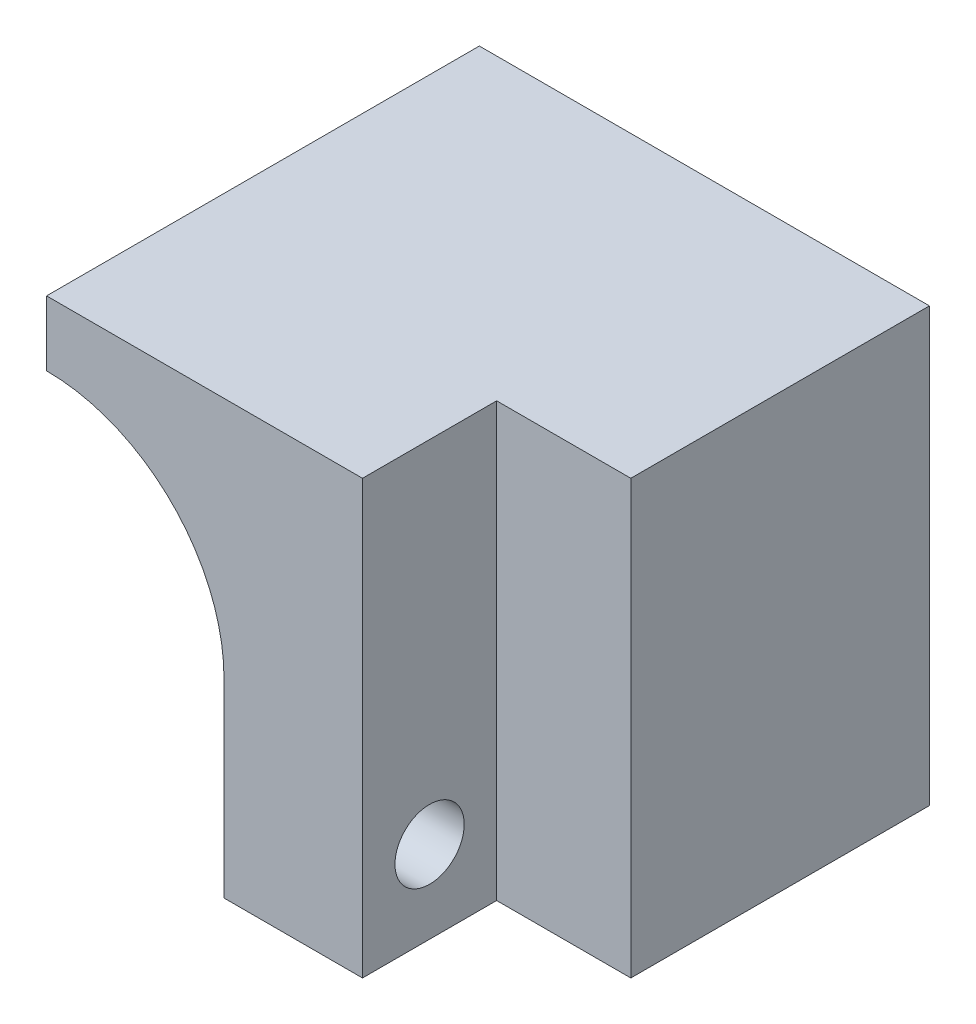
from build123d import *

# Parameters (mm, degrees)
CROQUIS1_W              = 20.8
CROQUIS1_H              = 20
SALIENTE_EXTRUIR1_DEPTH = 2
SALIENTE_EXTRUIR2_DEPTH = 11.8
SALIENTE_EXTRUIR3_DEPTH = 6.2
CORTAR_EXTRUIR1_REACH   = 16.6
CROQUIS4_R              = 1.6
CORTAR_EXTRUIR2_DEPTH   = 3


with BuildPart() as part:
    # Croquis1 → Saliente-Extruir1 (new body)
    with BuildSketch(Plane.XY):
        with Locations((10.4, -10)):
            Rectangle(CROQUIS1_W, CROQUIS1_H)
    extrude(amount=SALIENTE_EXTRUIR1_DEPTH)

    # Croquis2 → Saliente-Extruir2 (add)
    with BuildSketch(Plane.XY.offset(2)):
        with BuildLine():
            Line((8.2, -11.2), (8.2, -20))
            Line((8.2, -20), (20.8, -20))
            Line((20.8, -20), (20.8, 0))
            Line((20.8, 0), (0, 0))
            Line((0, 0), (0, -3))
            ThreePointArc((0, -3), (5.798275606, -5.401724394), (8.2, -11.2))
        make_face()
    extrude(amount=SALIENTE_EXTRUIR2_DEPTH)

    # Croquis3 → Saliente-Extruir3 (add)
    with BuildSketch(Plane.XY.offset(13.8)):
        with BuildLine():
            Line((14.6, -20), (14.6, 0))
            Line((14.6, 0), (0, 0))
            Line((0, 0), (0, -3))
            ThreePointArc((0, -3), (5.798275606, -5.401724394), (8.2, -11.2))
            Line((8.2, -11.2), (8.2, -20))
            Line((8.2, -20), (14.6, -20))
        make_face()
    extrude(amount=SALIENTE_EXTRUIR3_DEPTH)

    # Croquis4 → Cortar-Extruir1 (cut, up to next)
    with BuildSketch(Plane(origin=(14.6, 0, 0), x_dir=(0, 0, -1), z_dir=(1, 0, 0)), mode=Mode.PRIVATE) as cortar_extruir1_sk1:
        with Locations((-16.9, -16.2)):
            Circle(CROQUIS4_R)
    cortar_extruir1_tool1 = extrude(cortar_extruir1_sk1.sketch, amount=-CORTAR_EXTRUIR1_REACH, mode=Mode.PRIVATE) & part.part
    add(cortar_extruir1_tool1.solids().sort_by_distance((14.6, -16.2, 16.9))[0], mode=Mode.SUBTRACT)

    # Croquis5 → Cortar-Extruir2 (cut)
    with BuildSketch(Plane.ZY.offset(-8.2)):
        Polygon((16.9, -19.490896534), (19.75, -17.845448267), (19.75, -14.554551733), (16.9, -12.909103466), (14.05, -14.554551733), (14.05, -17.845448267), align=None)
    extrude(amount=-CORTAR_EXTRUIR2_DEPTH, mode=Mode.SUBTRACT)


solid = part.part
